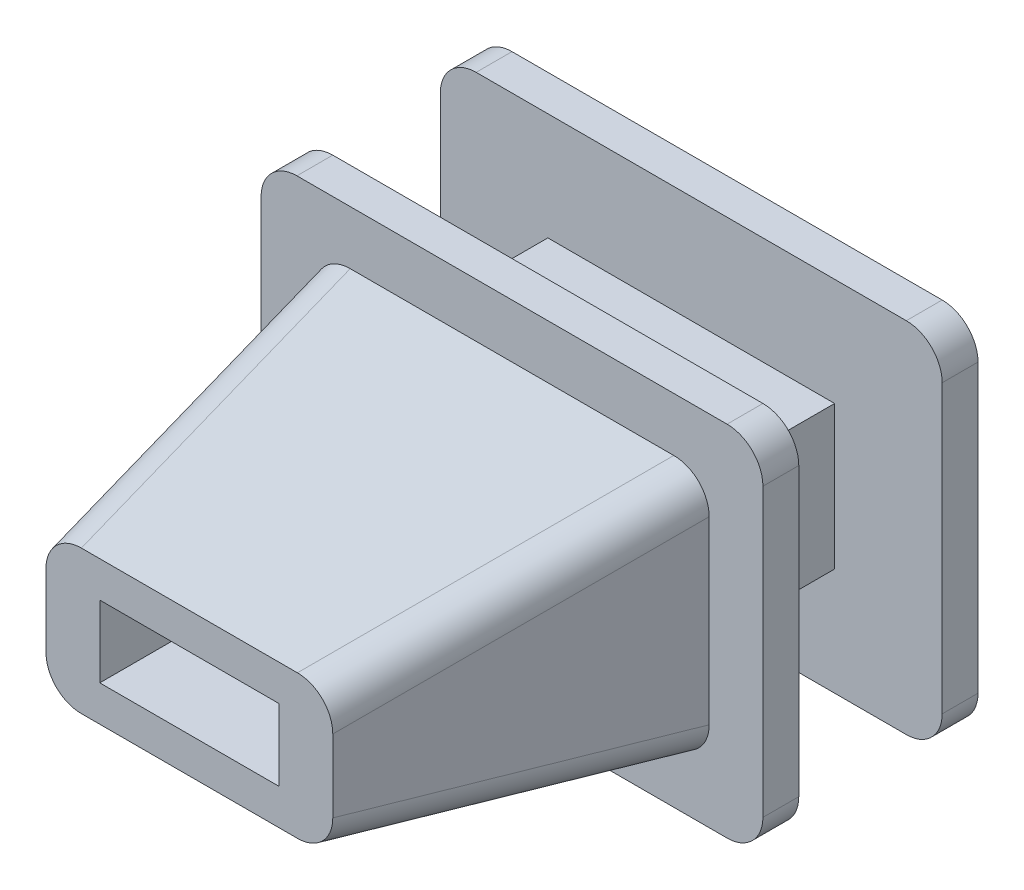
from build123d import *

# Parameters (mm, degrees)
ESQUISSE1_W             = 4
ESQUISSE1_H             = 2
BASE_EXTRUSION_DEPTH    = 2
BOSS_EXTRU_1_DEPTH      = 0.5
BOSS_EXTRU_2_DEPTH      = 0.5
ESQUISSE4_W             = 5.5
ESQUISSE4_H             = 3.5
ESQUISSE5_W             = 4
ESQUISSE5_H             = 2
CONG_1_R                = 0.5
ESQUISSE6_W             = 2.5
ESQUISSE6_H             = 1
ENL_V_MAT_EXTRU_1_DEPTH = 8.5


with BuildPart() as part:
    # Esquisse1 → Base-Extrusion (new body)
    with BuildSketch(Plane.XY):
        Rectangle(ESQUISSE1_W, ESQUISSE1_H)
    extrude(amount=BASE_EXTRUSION_DEPTH)

    # Esquisse2 → Boss.-Extru.1 (add)
    with BuildSketch(Plane(origin=(0, 0, 0), x_dir=(-1, 0, 0), z_dir=(0, 0, -1))):
        with BuildLine():
            Line((-3, 2.5), (3, 2.5))
            ThreePointArc((3, 2.5), (3.353553391, 2.353553391), (3.5, 2))
            Line((3.5, 2), (3.5, -2))
            ThreePointArc((3.5, -2), (3.353553391, -2.353553391), (3, -2.5))
            Line((3, -2.5), (-3, -2.5))
            ThreePointArc((-3, -2.5), (-3.353553391, -2.353553391), (-3.5, -2))
            Line((-3.5, -2), (-3.5, 2))
            ThreePointArc((-3.5, 2), (-3.353553391, 2.353553391), (-3, 2.5))
        make_face()
    extrude(amount=BOSS_EXTRU_1_DEPTH)

    # Esquisse3 → Boss.-Extru.2 (add)
    with BuildSketch(Plane.XY.offset(2)):
        with BuildLine():
            Line((-3, -2.5), (3, -2.5))
            ThreePointArc((3, -2.5), (3.353553391, -2.353553391), (3.5, -2))
            Line((3.5, -2), (3.5, 2))
            ThreePointArc((3.5, 2), (3.353553391, 2.353553391), (3, 2.5))
            Line((3, 2.5), (-3, 2.5))
            ThreePointArc((-3, 2.5), (-3.353553391, 2.353553391), (-3.5, 2))
            Line((-3.5, 2), (-3.5, -2))
            ThreePointArc((-3.5, -2), (-3.353553391, -2.353553391), (-3, -2.5))
        make_face()
    extrude(amount=BOSS_EXTRU_2_DEPTH)

    # Esquisse4 → Boss.-Lissage1 section 0
    with BuildSketch(Plane.XY.offset(2.5)):
        Rectangle(ESQUISSE4_W, ESQUISSE4_H)
    # Esquisse5 → Boss.-Lissage1 section 1
    with BuildSketch(Plane.XY.offset(7)):
        Rectangle(ESQUISSE5_W, ESQUISSE5_H)
    loft()

    # Congé1
    cong_1_edges = [part.edges().sort_by_distance(p)[0] for p in [
        (-2.375, 1.375, 4.75),
        (2.375, 1.375, 4.75),
        (-2.375, -1.375, 4.75),
        (2.375, -1.375, 4.75),
    ]]
    fillet(cong_1_edges, radius=CONG_1_R)

    # Esquisse6 → Enlèv. mat.-Extru.1 (cut, through all)
    with BuildSketch(Plane.XY.offset(7)):
        Rectangle(ESQUISSE6_W, ESQUISSE6_H)
    extrude(amount=-ENL_V_MAT_EXTRU_1_DEPTH, mode=Mode.SUBTRACT)


solid = part.part
